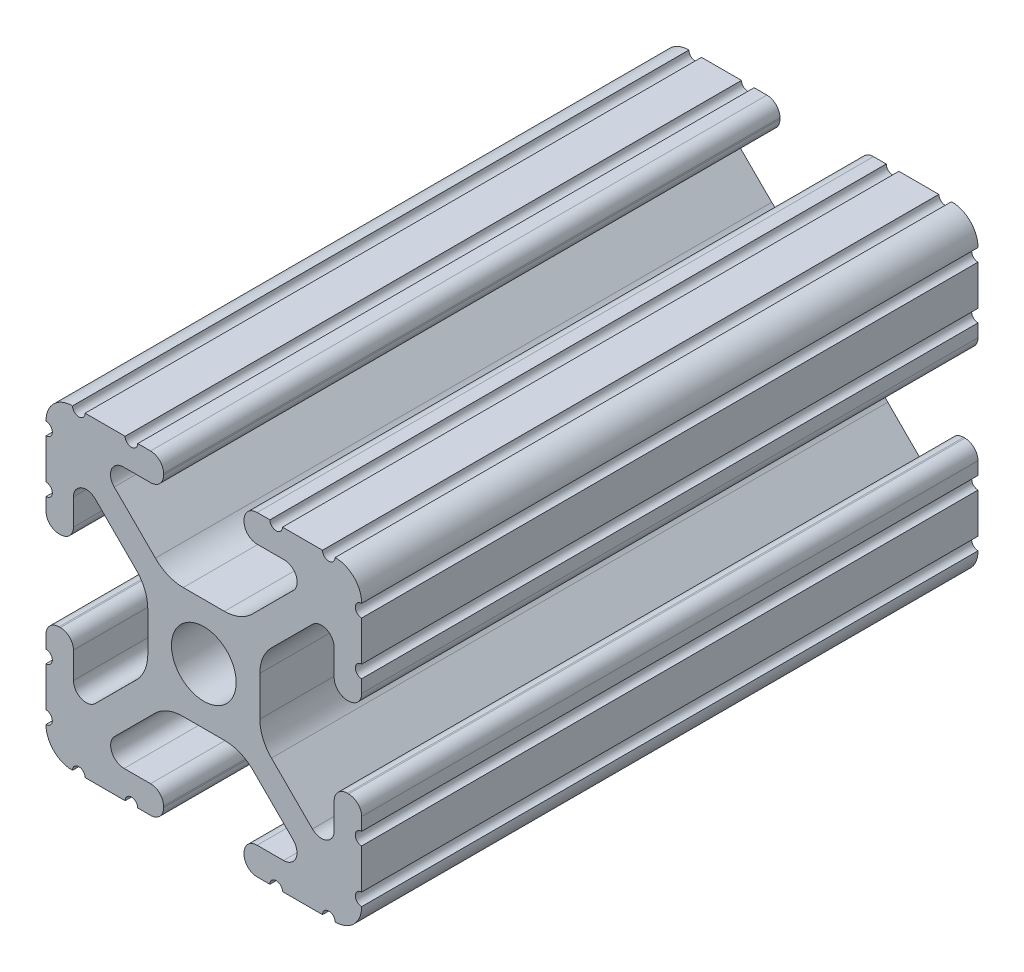
from build123d import *

# Parameters (mm, degrees)
SKETCH1_R               = 2.6035
BOSS_EXTRUDE1_DEPTH     = 457.2
CUT_EXTRUDE2_DEPTH      = 4.318
CUT_EXTRUDE2_DEPTH_BACK = 26.924
SKETCH4_W               = 10.066529056
SKETCH4_H               = 26.230878965
CUT_EXTRUDE3_DEPTH      = 26.4


with BuildPart() as part:
    # Sketch1 → Boss-Extrude1 (new body, symmetric)
    with BuildSketch(Plane.XY):
        with BuildLine():
            Line((-7.179650497, -8.645192506), (-3.952270251, -5.423690499))
            ThreePointArc((-3.952270251, -5.423690499), (-2.922936451, -4.736929036), (-1.709253557, -4.4958))
            Line((-1.709253557, -4.4958), (1.709253557, -4.4958))
            ThreePointArc((1.709253557, -4.4958), (2.922936451, -4.736929036), (3.952270251, -5.423690499))
            Line((3.952270251, -5.423690499), (7.179650497, -8.645192506))
            ThreePointArc((7.179650497, -8.645192506), (7.41473083, -9.822813117), (6.416408329, -10.4902))
            Line((6.416408329, -10.4902), (4.287512407, -10.4902))
            ThreePointArc((4.287512407, -10.4902), (3.54574862, -10.79744862), (3.2385, -11.539212407))
            Line((3.2385, -11.539212407), (3.2385, -11.650987593))
            ThreePointArc((3.2385, -11.650987593), (3.54574862, -12.39275138), (4.287512407, -12.7))
            Line((4.287512407, -12.7), (5.317126718, -12.7))
            ThreePointArc((5.317126718, -12.7), (5.825126718, -12.192), (6.333126718, -12.7))
            Line((6.333126718, -12.7), (9.550443118, -12.7))
            ThreePointArc((9.550443118, -12.7), (10.058366869, -12.192000006), (10.566443095, -12.699847501))
            ThreePointArc((10.566443095, -12.699847501), (12.082537762, -12.08250727), (12.699846982, -10.566399977))
            ThreePointArc((12.699846982, -10.566399977), (12.192000006, -10.058323491), (12.7, -9.5504))
            Line((12.7, -9.5504), (12.7, -6.3330836))
            ThreePointArc((12.7, -6.3330836), (12.192, -5.8250836), (12.7, -5.3170836))
            Line((12.7, -5.3170836), (12.7, -4.287469289))
            ThreePointArc((12.7, -4.287469289), (12.39275138, -3.545705502), (11.650987593, -3.238456882))
            Line((11.650987593, -3.238456882), (11.539212407, -3.238456882))
            ThreePointArc((11.539212407, -3.238456882), (10.79744862, -3.545705502), (10.4902, -4.287469289))
            Line((10.4902, -4.287469289), (10.4902, -6.402089023))
            ThreePointArc((10.4902, -6.402089023), (9.856505071, -7.351067942), (8.737131347, -7.129408934))
            Line((8.737131347, -7.129408934), (5.441005833, -3.840816462))
            ThreePointArc((5.441005833, -3.840816462), (4.750877967, -2.809883091), (4.5085, -1.593185507))
            Line((4.5085, -1.593185507), (4.5085, 1.593185507))
            ThreePointArc((4.5085, 1.593185507), (4.750877967, 2.809883091), (5.441005833, 3.840816462))
            Line((5.441005833, 3.840816462), (8.737131347, 7.129408934))
            ThreePointArc((8.737131347, 7.129408934), (9.856505071, 7.351067942), (10.4902, 6.402089023))
            Line((10.4902, 6.402089023), (10.4902, 4.287469289))
            ThreePointArc((10.4902, 4.287469289), (10.79744862, 3.545705502), (11.539212407, 3.238456882))
            Line((11.539212407, 3.238456882), (11.650987593, 3.238456882))
            ThreePointArc((11.650987593, 3.238456882), (12.39275138, 3.545705502), (12.7, 4.287469289))
            Line((12.7, 4.287469289), (12.7, 5.3170836))
            ThreePointArc((12.7, 5.3170836), (12.192, 5.8250836), (12.7, 6.3330836))
            Line((12.7, 6.3330836), (12.7, 9.5504))
            ThreePointArc((12.7, 9.5504), (12.192000006, 10.058323491), (12.699846982, 10.566399977))
            ThreePointArc((12.699846982, 10.566399977), (12.082537762, 12.08250727), (10.566443095, 12.699847501))
            ThreePointArc((10.566443095, 12.699847501), (10.058366869, 12.192000006), (9.550443118, 12.7))
            Line((9.550443118, 12.7), (6.333126718, 12.7))
            ThreePointArc((6.333126718, 12.7), (5.825126718, 12.192), (5.317126718, 12.7))
            Line((5.317126718, 12.7), (4.287512407, 12.7))
            ThreePointArc((4.287512407, 12.7), (3.54574862, 12.39275138), (3.2385, 11.650987593))
            Line((3.2385, 11.650987593), (3.2385, 11.539212407))
            ThreePointArc((3.2385, 11.539212407), (3.54574862, 10.79744862), (4.287512407, 10.4902))
            Line((4.287512407, 10.4902), (6.476788598, 10.4902))
            ThreePointArc((6.476788598, 10.4902), (7.432222385, 9.85140422), (7.207036008, 8.724370562))
            Line((7.207036008, 8.724370562), (3.898272566, 5.423169045))
            ThreePointArc((3.898272566, 5.423169045), (2.869120213, 4.736787962), (1.655778399, 4.4958))
            Line((1.655778399, 4.4958), (-1.655778399, 4.4958))
            ThreePointArc((-1.655778399, 4.4958), (-2.869120213, 4.736787962), (-3.898272566, 5.423169045))
            Line((-3.898272566, 5.423169045), (-7.207036008, 8.724370562))
            ThreePointArc((-7.207036008, 8.724370562), (-7.432222385, 9.85140422), (-6.476788598, 10.4902))
            Line((-6.476788598, 10.4902), (-4.287512407, 10.4902))
            ThreePointArc((-4.287512407, 10.4902), (-3.54574862, 10.79744862), (-3.2385, 11.539212407))
            Line((-3.2385, 11.539212407), (-3.2385, 11.650987593))
            ThreePointArc((-3.2385, 11.650987593), (-3.54574862, 12.39275138), (-4.287512407, 12.7))
            Line((-4.287512407, 12.7), (-5.317126718, 12.7))
            ThreePointArc((-5.317126718, 12.7), (-5.825126718, 12.192), (-6.333126718, 12.7))
            Line((-6.333126718, 12.7), (-9.550443118, 12.7))
            ThreePointArc((-9.550443118, 12.7), (-10.058366869, 12.192000006), (-10.566443095, 12.699847501))
            ThreePointArc((-10.566443095, 12.699847501), (-12.082537762, 12.08250727), (-12.699846982, 10.566399977))
            ThreePointArc((-12.699846982, 10.566399977), (-12.192000006, 10.058323491), (-12.7, 9.5504))
            Line((-12.7, 9.5504), (-12.7, 6.3330836))
            ThreePointArc((-12.7, 6.3330836), (-12.192, 5.8250836), (-12.7, 5.3170836))
            Line((-12.7, 5.3170836), (-12.7, 4.287469289))
            ThreePointArc((-12.7, 4.287469289), (-12.39275138, 3.545705502), (-11.650987593, 3.238456882))
            Line((-11.650987593, 3.238456882), (-11.539212407, 3.238456882))
            ThreePointArc((-11.539212407, 3.238456882), (-10.79744862, 3.545705502), (-10.4902, 4.287469289))
            Line((-10.4902, 4.287469289), (-10.4902, 6.402089023))
            ThreePointArc((-10.4902, 6.402089023), (-9.856505071, 7.351067942), (-8.737131347, 7.129408934))
            Line((-8.737131347, 7.129408934), (-5.441005833, 3.840816462))
            ThreePointArc((-5.441005833, 3.840816462), (-4.750877967, 2.809883091), (-4.5085, 1.593185507))
            Line((-4.5085, 1.593185507), (-4.5085, -1.593185507))
            ThreePointArc((-4.5085, -1.593185507), (-4.750877967, -2.809883091), (-5.441005833, -3.840816462))
            Line((-5.441005833, -3.840816462), (-8.737131347, -7.129408934))
            ThreePointArc((-8.737131347, -7.129408934), (-9.856505071, -7.351067942), (-10.4902, -6.402089023))
            Line((-10.4902, -6.402089023), (-10.4902, -4.287469289))
            ThreePointArc((-10.4902, -4.287469289), (-10.79744862, -3.545705502), (-11.539212407, -3.238456882))
            Line((-11.539212407, -3.238456882), (-11.650987593, -3.238456882))
            ThreePointArc((-11.650987593, -3.238456882), (-12.39275138, -3.545705502), (-12.7, -4.287469289))
            Line((-12.7, -4.287469289), (-12.7, -5.3170836))
            ThreePointArc((-12.7, -5.3170836), (-12.192, -5.8250836), (-12.7, -6.3330836))
            Line((-12.7, -6.3330836), (-12.7, -9.5504))
            ThreePointArc((-12.7, -9.5504), (-12.192000006, -10.058323491), (-12.699846982, -10.566399977))
            ThreePointArc((-12.699846982, -10.566399977), (-12.082537762, -12.08250727), (-10.566443095, -12.699847501))
            ThreePointArc((-10.566443095, -12.699847501), (-10.058366869, -12.192000006), (-9.550443118, -12.7))
            Line((-9.550443118, -12.7), (-6.333126718, -12.7))
            ThreePointArc((-6.333126718, -12.7), (-5.825126718, -12.192), (-5.317126718, -12.7))
            Line((-5.317126718, -12.7), (-4.287512407, -12.7))
            ThreePointArc((-4.287512407, -12.7), (-3.54574862, -12.39275138), (-3.2385, -11.650987593))
            Line((-3.2385, -11.650987593), (-3.2385, -11.539212407))
            ThreePointArc((-3.2385, -11.539212407), (-3.54574862, -10.79744862), (-4.287512407, -10.4902))
            Line((-4.287512407, -10.4902), (-6.416408329, -10.4902))
            ThreePointArc((-6.416408329, -10.4902), (-7.41473083, -9.822813117), (-7.179650497, -8.645192506))
        make_face()
        Circle(SKETCH1_R, mode=Mode.SUBTRACT)
    extrude(amount=BOSS_EXTRUDE1_DEPTH, both=True)

    # Sketch3 → Cut-Extrude2 (cut, two sides)
    with BuildSketch(Plane.ZY.offset(12.7)) as cut_extrude2_sk:
        Polygon((-203.2, -27.552777595), (-203.2, 21.158109763), (-461.090893327, 21.158109763), (-461.090893327, -25.4), align=None)
    extrude(amount=CUT_EXTRUDE2_DEPTH, mode=Mode.SUBTRACT)
    extrude(cut_extrude2_sk.sketch, amount=-CUT_EXTRUDE2_DEPTH_BACK, mode=Mode.SUBTRACT)

    # Sketch4 → Cut-Extrude3 (cut, through all)
    with BuildSketch(Plane(origin=(12.7, 0, 0), x_dir=(0, 0, -1), z_dir=(1, 0, 0))):
        Polygon((144.651128895, 14.668633048), (144.651128895, -33.454509464), (-421.914129737, -33.454509464), (-459.790894846, -33.454509464), (-459.790894846, 14.668633048), (-421.914129737, 14.668633048), align=None)
        with Locations((199.285393072, 0.039458439)):
            Rectangle(SKETCH4_W, SKETCH4_H)
    extrude(amount=-CUT_EXTRUDE3_DEPTH, mode=Mode.SUBTRACT)


solid = part.part
